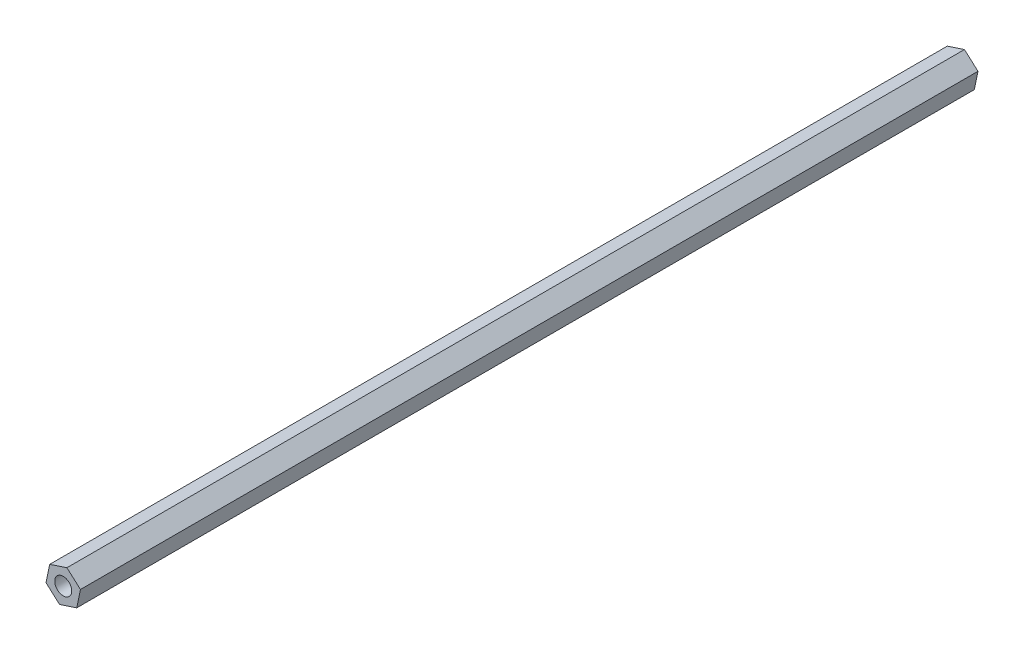
from build123d import *

# Parameters (mm, degrees)
SALIENTE_EXTRUIR1_DEPTH = 180
CROQUIS2_R              = 1.7
CORTAR_EXTRUIR1_DEPTH   = 181


with BuildPart() as part:
    # Croquis1 → Saliente-Extruir1 (new body)
    with BuildSketch(Plane.XY):
        Polygon((3.454026158, 1.140045307), (0.739704881, 3.561297051), (-2.714321276, 2.421251744), (-3.454026158, -1.140045307), (-0.739704881, -3.561297051), (2.714321276, -2.421251744), align=None)
    extrude(amount=SALIENTE_EXTRUIR1_DEPTH)

    # Croquis2 → Cortar-Extruir1 (cut, through all)
    with BuildSketch(Plane.XY.offset(180)):
        Circle(CROQUIS2_R)
    extrude(amount=-CORTAR_EXTRUIR1_DEPTH, mode=Mode.SUBTRACT)


solid = part.part
